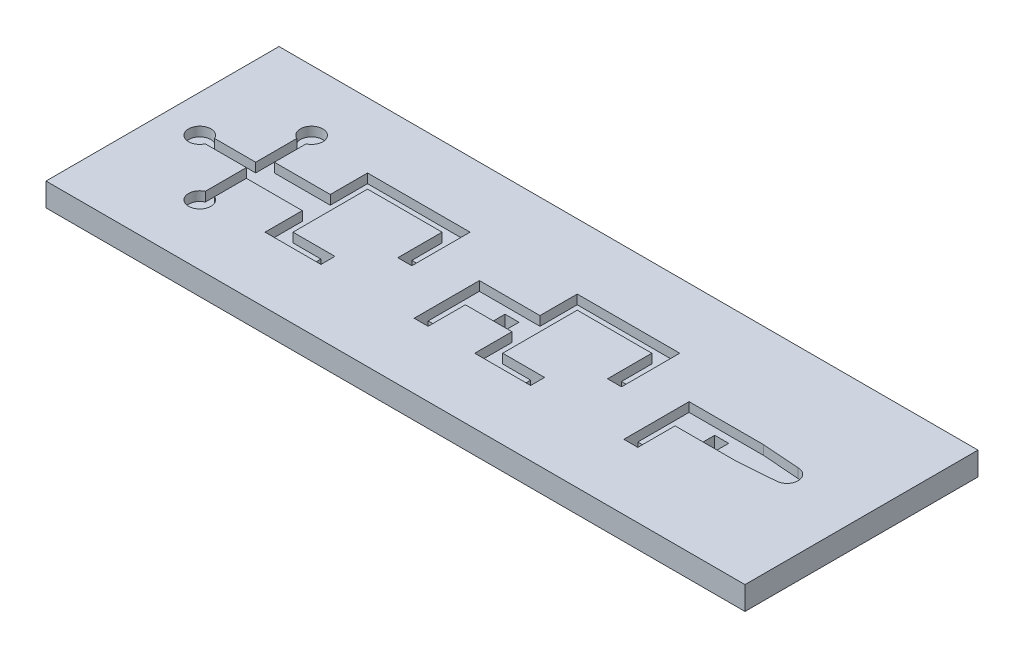
from build123d import *

# Parameters (mm, degrees)
SKETCH2_W           = 75
SKETCH2_H           = 25
BOSS_EXTRUDE1_DEPTH = 2.5
CUT_EXTRUDE1_DEPTH  = 1
SKETCH3_W           = 1.5
SKETCH3_H           = 1.5
CUT_EXTRUDE2_DEPTH  = 3.5
SKETCH4_W           = 0.5
SKETCH4_H           = 1
CUT_EXTRUDE3_DEPTH  = 1


with BuildPart() as part:
    # Sketch2 → Boss-Extrude1 (new body)
    with BuildSketch(Plane(origin=(0, 0, 0), x_dir=(1, 0, 0), z_dir=(0, 1, 0))):
        with Locations((8.414308894, -4.186562074)):
            Rectangle(SKETCH2_W, SKETCH2_H)
    extrude(amount=-BOSS_EXTRUDE1_DEPTH)

    # Sketch1 → Cut-Extrude1 (cut)
    with BuildSketch(Plane(origin=(0, 0, 0), x_dir=(1, 0, 0), z_dir=(0, 1, 0))):
        Polygon((-12.585691106, -2.686562074), (-19.085691106, -2.686562074), (-19.085691106, -5.686562074), (-12.585691106, -5.686562074), (-12.585691106, -9.686562074), (-6.585691106, -9.686562074), (-6.585691106, -8.186562074), (-11.085691106, -8.186562074), (-11.085691106, -0.186562074), (-3.085691106, -0.186562074), (-3.085691106, -4.936562074), (-1.585691106, -4.936562074), (-1.585691106, 1.313437926), (-12.585691106, 1.313437926), align=None)
        Polygon((9.914308894, -2.686562074), (3.414308894, -2.686562074), (3.414308894, -9.686562074), (4.914308894, -9.686562074), (4.914308894, -5.686562074), (9.914308894, -5.686562074), (9.914308894, -9.686562074), (15.914308894, -9.686562074), (15.914308894, -8.186562074), (11.414308894, -8.186562074), (11.414308894, -0.186562074), (19.414308894, -0.186562074), (19.414308894, -4.936562074), (20.914308894, -4.936562074), (20.914308894, 1.313437926), (9.914308894, 1.313437926), align=None)
        Polygon((33.914308894, -2.686562074), (25.914308894, -2.686562074), (25.914308894, -9.686562074), (27.414308894, -9.686562074), (27.414308894, -5.686562074), (33.914308894, -5.686562074), align=None)
    extrude(amount=-CUT_EXTRUDE1_DEPTH, mode=Mode.SUBTRACT)

    # Sketch3 → Cut-Extrude2 (cut, through all)
    with BuildSketch(Plane(origin=(0, 0, 0), x_dir=(1, 0, 0), z_dir=(0, 1, 0))):
        with Locations((-7.335691106, -8.936562074)):
            Rectangle(SKETCH3_W, SKETCH3_H)
        with Locations((-2.335691106, -4.186562074)):
            Rectangle(SKETCH3_W, SKETCH3_H)
        with Locations((4.164308894, -8.936562074)):
            Rectangle(SKETCH3_W, SKETCH3_H)
        with Locations((30.164308894, -4.186562074)):
            Rectangle(SKETCH3_W, SKETCH3_H)
        with Locations((7.664308894, -4.186562074)):
            Rectangle(SKETCH3_W, SKETCH3_H)
        with Locations((15.164308894, -8.936562074)):
            Rectangle(SKETCH3_W, SKETCH3_H)
        with Locations((20.164308894, -4.186562074)):
            Rectangle(SKETCH3_W, SKETCH3_H)
        with Locations((26.664308894, -8.936562074)):
            Rectangle(SKETCH3_W, SKETCH3_H)
    extrude(amount=-CUT_EXTRUDE2_DEPTH, mode=Mode.SUBTRACT)

    # Sketch4 → Cut-Extrude3 (cut)
    with BuildSketch(Plane(origin=(0, 0, 0), x_dir=(1, 0, 0), z_dir=(0, 1, 0))):
        with BuildLine():
            ThreePointArc((37.914308894, -5.386562074), (39.114308894, -4.186562074), (37.914308894, -2.986562074))
            Line((37.914308894, -2.986562074), (33.914308894, -2.686562074))
            Line((33.914308894, -2.686562074), (33.914308894, -5.686562074))
            Line((33.914308894, -5.686562074), (37.914308894, -5.386562074))
        make_face()
        with BuildLine():
            ThreePointArc((-17.885691106, 1.813437926), (-19.733765176, 2.82338842), (-19.585691106, 0.722566715))
            Line((-19.585691106, 0.722566715), (-19.585691106, 1.813437926))
            ThreePointArc((-19.585691106, 1.813437926), (-19.085691106, 2.313437926), (-18.585691106, 1.813437926))
            Line((-18.585691106, 1.813437926), (-18.585691106, 0.722566715))
            ThreePointArc((-18.585691106, 0.722566715), (-18.075740612, 1.165363856), (-17.885691106, 1.813437926))
        make_face()
        with BuildLine():
            Line((-19.585691106, 1.813437926), (-19.585691106, 0.722566715))
            ThreePointArc((-19.585691106, 0.722566715), (-19.085691106, 0.613437926), (-18.585691106, 0.722566715))
            Line((-18.585691106, 0.722566715), (-18.585691106, 1.813437926))
            ThreePointArc((-18.585691106, 1.813437926), (-19.085691106, 2.313437926), (-19.585691106, 1.813437926))
        make_face()
        with BuildLine():
            Line((-19.585691106, 0.722566715), (-19.585691106, -3.686562074))
            Line((-19.585691106, -3.686562074), (-19.085691106, -3.686562074))
            Line((-19.085691106, -3.686562074), (-19.085691106, -2.686562074))
            Line((-19.085691106, -2.686562074), (-18.585691106, -2.686562074))
            Line((-18.585691106, -2.686562074), (-18.585691106, 0.722566715))
            ThreePointArc((-18.585691106, 0.722566715), (-19.085691106, 0.613437926), (-19.585691106, 0.722566715))
        make_face()
        with BuildLine():
            Line((-23.994819895, -4.686562074), (-25.085691106, -4.686562074))
            ThreePointArc((-25.085691106, -4.686562074), (-25.585691106, -4.186562074), (-25.085691106, -3.686562074))
            Line((-25.085691106, -3.686562074), (-23.994819895, -3.686562074))
            ThreePointArc((-23.994819895, -3.686562074), (-26.285691106, -4.186562074), (-23.994819895, -4.686562074))
        make_face()
        with BuildLine():
            ThreePointArc((-25.085691106, -3.686562074), (-25.585691106, -4.186562074), (-25.085691106, -4.686562074))
            Line((-25.085691106, -4.686562074), (-23.994819895, -4.686562074))
            ThreePointArc((-23.994819895, -4.686562074), (-23.913290694, -4.442447347), (-23.885691106, -4.186562074))
            ThreePointArc((-23.885691106, -4.186562074), (-23.913290694, -3.9306768), (-23.994819895, -3.686562074))
            Line((-23.994819895, -3.686562074), (-25.085691106, -3.686562074))
        make_face()
        with BuildLine():
            ThreePointArc((-23.885691106, -4.186562074), (-23.913290694, -4.442447347), (-23.994819895, -4.686562074))
            Line((-23.994819895, -4.686562074), (-19.585691106, -4.686562074))
            Line((-19.585691106, -4.686562074), (-19.585691106, -3.686562074))
            Line((-19.585691106, -3.686562074), (-23.994819895, -3.686562074))
            ThreePointArc((-23.994819895, -3.686562074), (-23.913290694, -3.9306768), (-23.885691106, -4.186562074))
        make_face()
        with Locations((-19.335691106, -4.186562074)):
            Rectangle(SKETCH4_W, SKETCH4_H)
        with BuildLine():
            Line((-19.085691106, -3.686562074), (-19.085691106, -4.686562074))
            ThreePointArc((-19.085691106, -4.686562074), (-18.732137716, -4.540115464), (-18.585691106, -4.186562074))
            ThreePointArc((-18.585691106, -4.186562074), (-18.732137716, -3.833008683), (-19.085691106, -3.686562074))
        make_face()
        with BuildLine():
            ThreePointArc((-19.085691106, -3.686562074), (-18.732137716, -3.833008683), (-18.585691106, -4.186562074))
            Line((-18.585691106, -4.186562074), (-18.585691106, -2.686562074))
            Line((-18.585691106, -2.686562074), (-19.085691106, -2.686562074))
            Line((-19.085691106, -2.686562074), (-19.085691106, -3.686562074))
        make_face()
        with BuildLine():
            Line((-19.585691106, -10.186562074), (-19.585691106, -9.095690862))
            ThreePointArc((-19.585691106, -9.095690862), (-19.733765176, -11.196512568), (-17.885691106, -10.186562074))
            ThreePointArc((-17.885691106, -10.186562074), (-18.075740612, -9.538488004), (-18.585691106, -9.095690862))
            Line((-18.585691106, -9.095690862), (-18.585691106, -10.186562074))
            ThreePointArc((-18.585691106, -10.186562074), (-19.085691106, -10.686562074), (-19.585691106, -10.186562074))
        make_face()
        with BuildLine():
            ThreePointArc((-18.585691106, -9.095690862), (-19.085691106, -8.986562074), (-19.585691106, -9.095690862))
            Line((-19.585691106, -9.095690862), (-19.585691106, -10.186562074))
            ThreePointArc((-19.585691106, -10.186562074), (-19.085691106, -10.686562074), (-18.585691106, -10.186562074))
            Line((-18.585691106, -10.186562074), (-18.585691106, -9.095690862))
        make_face()
        with BuildLine():
            Line((-19.085691106, -4.686562074), (-19.585691106, -4.686562074))
            Line((-19.585691106, -4.686562074), (-19.585691106, -9.095690862))
            ThreePointArc((-19.585691106, -9.095690862), (-19.085691106, -8.986562074), (-18.585691106, -9.095690862))
            Line((-18.585691106, -9.095690862), (-18.585691106, -5.686562074))
            Line((-18.585691106, -5.686562074), (-19.085691106, -5.686562074))
            Line((-19.085691106, -5.686562074), (-19.085691106, -4.686562074))
        make_face()
        with BuildLine():
            ThreePointArc((-18.585691106, -4.186562074), (-18.732137716, -4.540115464), (-19.085691106, -4.686562074))
            Line((-19.085691106, -4.686562074), (-19.085691106, -5.686562074))
            Line((-19.085691106, -5.686562074), (-18.585691106, -5.686562074))
            Line((-18.585691106, -5.686562074), (-18.585691106, -4.186562074))
        make_face()
    extrude(amount=-CUT_EXTRUDE3_DEPTH, mode=Mode.SUBTRACT)


solid = part.part
